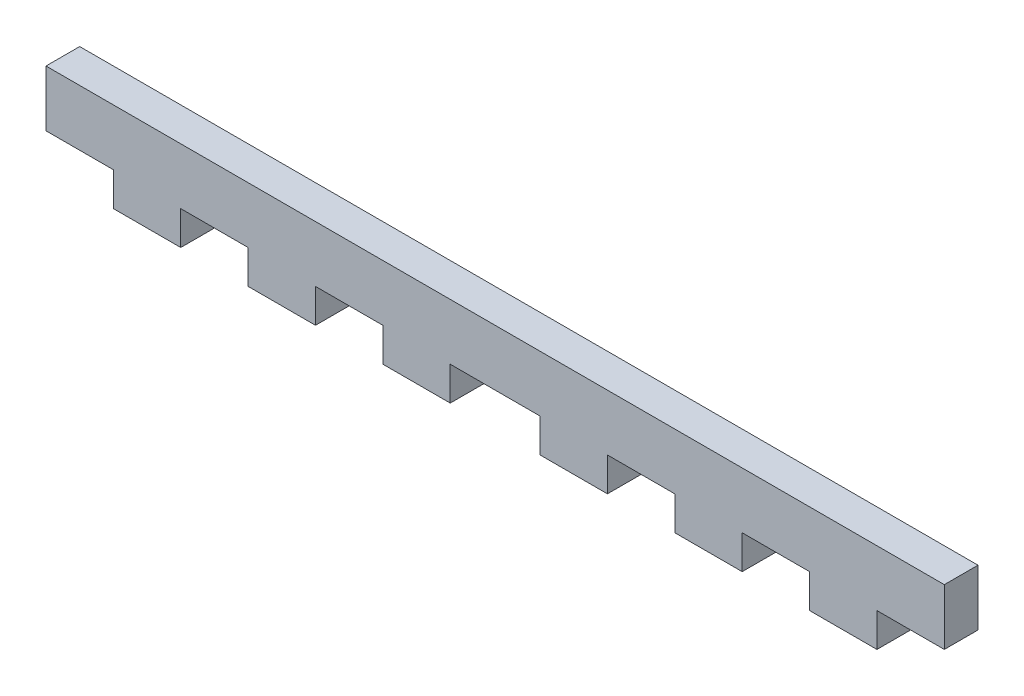
from build123d import *

# Parameters (mm, degrees)
SKETCH1_W           = 80
SKETCH1_H           = 5
BOSS_EXTRUDE1_DEPTH = 3
SKETCH2_W           = 6
SKETCH2_H           = 3
BOSS_EXTRUDE2_DEPTH = 3


with BuildPart() as part:
    # Sketch1 → Boss-Extrude1 (new body)
    with BuildSketch(Plane.XY):
        with Locations((6.679907864, -8.231689836)):
            Rectangle(SKETCH1_W, SKETCH1_H)
    extrude(amount=BOSS_EXTRUDE1_DEPTH)

    # Sketch2 → Boss-Extrude2 (add)
    with BuildSketch(Plane.XY.offset(3)):
        with Locations((-24.320092136, -12.231689836)):
            Rectangle(SKETCH2_W, SKETCH2_H)
        with Locations((37.679907864, -12.231689836)):
            Rectangle(SKETCH2_W, SKETCH2_H)
        with Locations((-12.320092136, -12.231689836)):
            Rectangle(SKETCH2_W, SKETCH2_H)
        with Locations((25.679907864, -12.231689836)):
            Rectangle(SKETCH2_W, SKETCH2_H)
        with Locations((-0.320092136, -12.231689836)):
            Rectangle(SKETCH2_W, SKETCH2_H)
        with Locations((13.679907864, -12.231689836)):
            Rectangle(SKETCH2_W, SKETCH2_H)
    extrude(amount=-BOSS_EXTRUDE2_DEPTH)


solid = part.part
